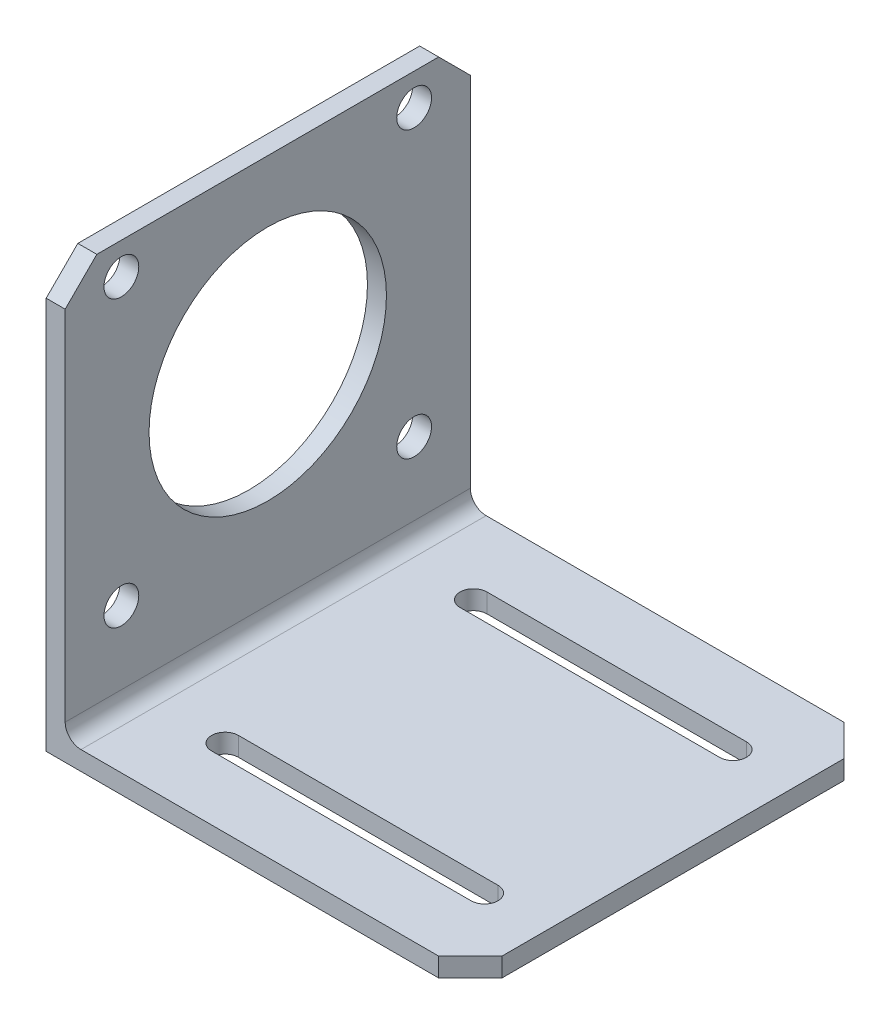
from build123d import *

# Parameters (mm, degrees)
BOSS_EXTRUDE1_DEPTH = 65.024
CUT_EXTRUDE1_DEPTH  = 65.024
SKETCH3_R           = 19.05
SKETCH3_R_2         = 2.794
CUT_EXTRUDE2_DEPTH  = 65.024
FILLET1_R           = 2.54
CHAMFER1_SIZE       = 5.08


with BuildPart() as part:
    # Sketch1 → Boss-Extrude1 (new body)
    with BuildSketch(Plane.XY):
        Polygon((-1.524, 32.512), (1.524, 32.512), (1.524, -32.512), (66.548, -32.512), (66.548, -35.56), (-1.524, -35.56), (-1.524, -32.512), align=None)
    extrude(amount=-BOSS_EXTRUDE1_DEPTH)

    # Sketch2 → Cut-Extrude1 (cut)
    with BuildSketch(Plane(origin=(0, -32.512, 0), x_dir=(1, 0, 0), z_dir=(0, 1, 0))):
        with BuildLine():
            Line((14.732, 14.605), (56.388, 14.605))
            ThreePointArc((56.388, 14.605), (58.547, 12.446), (56.388, 10.287))
            Line((56.388, 10.287), (14.732, 10.287))
            ThreePointArc((14.732, 10.287), (12.573, 12.446), (14.732, 14.605))
        make_face()
        with BuildLine():
            Line((14.732, 54.483), (56.388, 54.483))
            ThreePointArc((56.388, 54.483), (58.547, 52.324), (56.388, 50.165))
            Line((56.388, 50.165), (14.732, 50.165))
            ThreePointArc((14.732, 50.165), (12.573, 52.324), (14.732, 54.483))
        make_face()
    extrude(amount=-CUT_EXTRUDE1_DEPTH, mode=Mode.SUBTRACT)

    # Sketch3 → Cut-Extrude2 (cut)
    with BuildSketch(Plane.ZY.offset(1.524)):
        with Locations((-32.512, 3.556)):
            Circle(SKETCH3_R)
        with Locations((-56.007, -18.288)):
            Circle(SKETCH3_R_2)
        with Locations((-9.017, -18.288)):
            Circle(SKETCH3_R_2)
        with Locations((-9.017, 27.432)):
            Circle(SKETCH3_R_2)
        with Locations((-56.007, 27.432)):
            Circle(SKETCH3_R_2)
    extrude(amount=-CUT_EXTRUDE2_DEPTH, mode=Mode.SUBTRACT)

    # Fillet1
    fillet1_edges = [part.edges().sort_by_distance(p)[0] for p in [
        (1.524, -32.512, -32.512),
    ]]
    fillet(fillet1_edges, radius=FILLET1_R)

    # Chamfer1
    chamfer1_edges = [part.edges().sort_by_distance(p)[0] for p in [
        (0, 32.512, -65.024),
        (66.548, -34.036, -65.024),
        (66.548, -34.036, 0),
        (0, 32.512, 0),
    ]]
    chamfer(chamfer1_edges, length=CHAMFER1_SIZE)


solid = part.part
